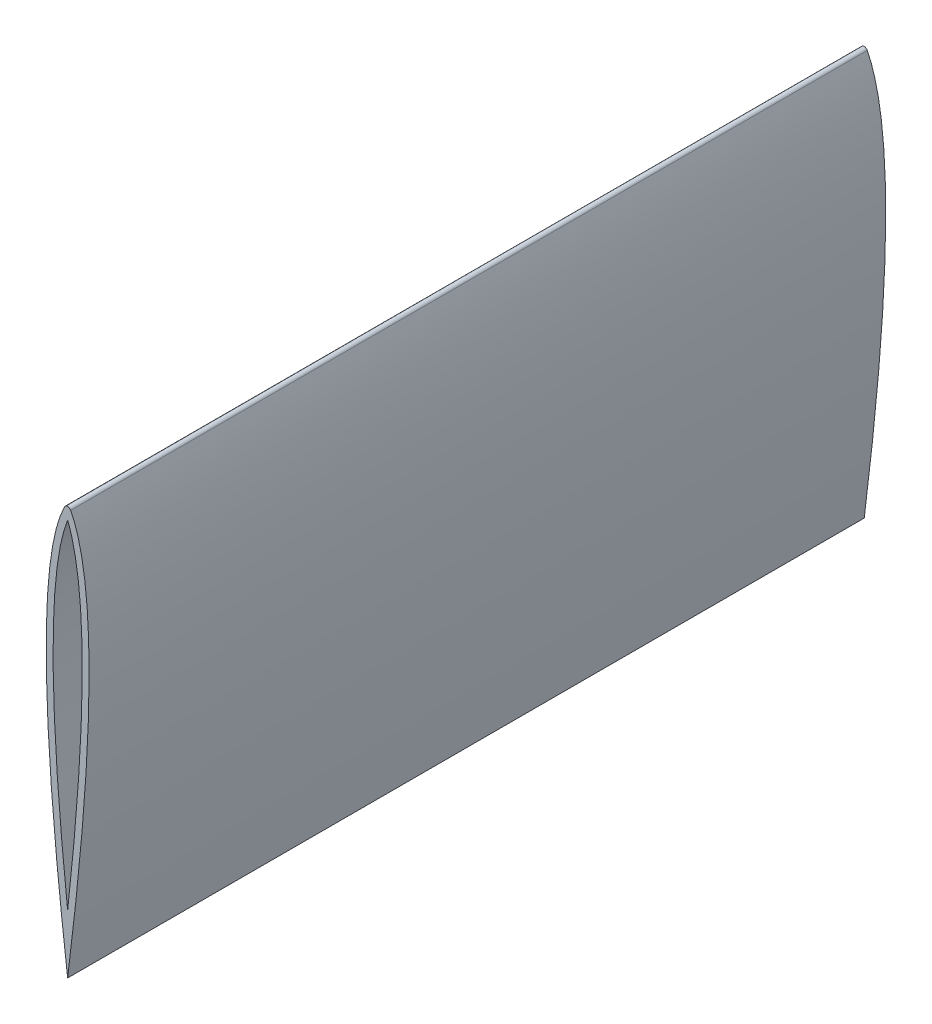
from build123d import *

# Parameters (mm, degrees)
BOSS_EXTRUDE1_DEPTH = 294.64


with BuildPart() as part:
    # Sketch1 → Boss-Extrude1 (new, symmetric)
    with BuildSketch(Plane.XY):
        with BuildLine():
            ThreePointArc((-2.267771894, 148.348367024), (0, 149.744334404), (2.267771894, 148.348367024))
            add(Edge.make_bspline(
                [(2.267771894, 148.348367024), (30.572440123, 92.24111101), (0, -152.4)],
                knots=[0, 0, 0, 1, 1, 1], degree=2))
            add(Edge.make_bspline(
                [(-2.267771894, 148.348367024), (-30.572440123, 92.24111101), (0, -152.4)],
                knots=[0, 0, 0, 1, 1, 1], degree=2))
        make_face()
        with BuildLine():
            add(Edge.make_bspline(
                [(0, 140.978035645), (3.918482074, 131.156065717), (8.169378172, 106.05556313), (10.242574642, 81.433345605), (11.145665597, 45.040166844), (8.163737965, -35.508846412), (0, -109.12531842)],
                knots=[0.045526815, 0.045526815, 0.045526815, 0.20753057, 0.315533073, 0.423535576, 0.585539331, 0.909546841, 0.909546841, 0.909546841], degree=2))
            add(Edge.make_bspline(
                [(0, -109.12531842), (-8.163737965, -35.508846412), (-11.145665597, 45.040166844), (-10.242574642, 81.433345605), (-8.169378172, 106.05556313), (-3.918482074, 131.156065717), (0, 140.978035645)],
                knots=[0.045526815, 0.045526815, 0.045526815, 0.369534325, 0.53153808, 0.639540583, 0.747543086, 0.909546841, 0.909546841, 0.909546841], degree=2))
        make_face(mode=Mode.SUBTRACT)
    extrude(amount=BOSS_EXTRUDE1_DEPTH, both=True)


solid = part.part
